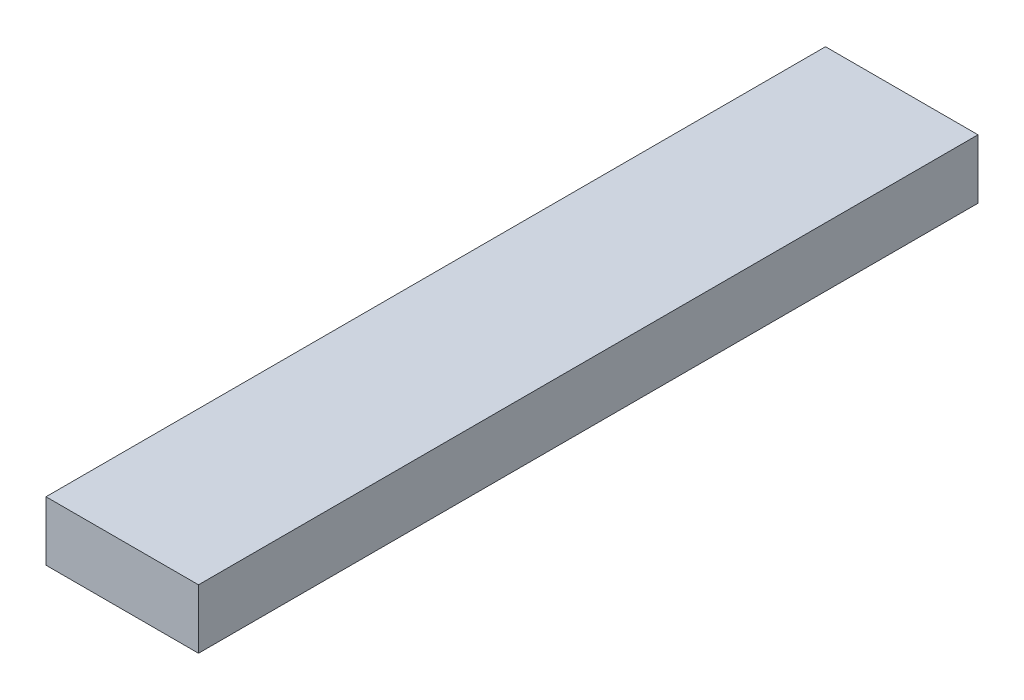
from build123d import *

# Parameters (mm, degrees)
CROQUIS1_W              = 9
CROQUIS1_H              = 3.5
SALIENTE_EXTRUIR1_DEPTH = 46


with BuildPart() as part:
    # Croquis1 → Saliente-Extruir1 (new body)
    with BuildSketch(Plane.XY):
        with Locations((-67.054930642, 7.267721006)):
            Rectangle(CROQUIS1_W, CROQUIS1_H)
    extrude(amount=SALIENTE_EXTRUIR1_DEPTH)


solid = part.part
